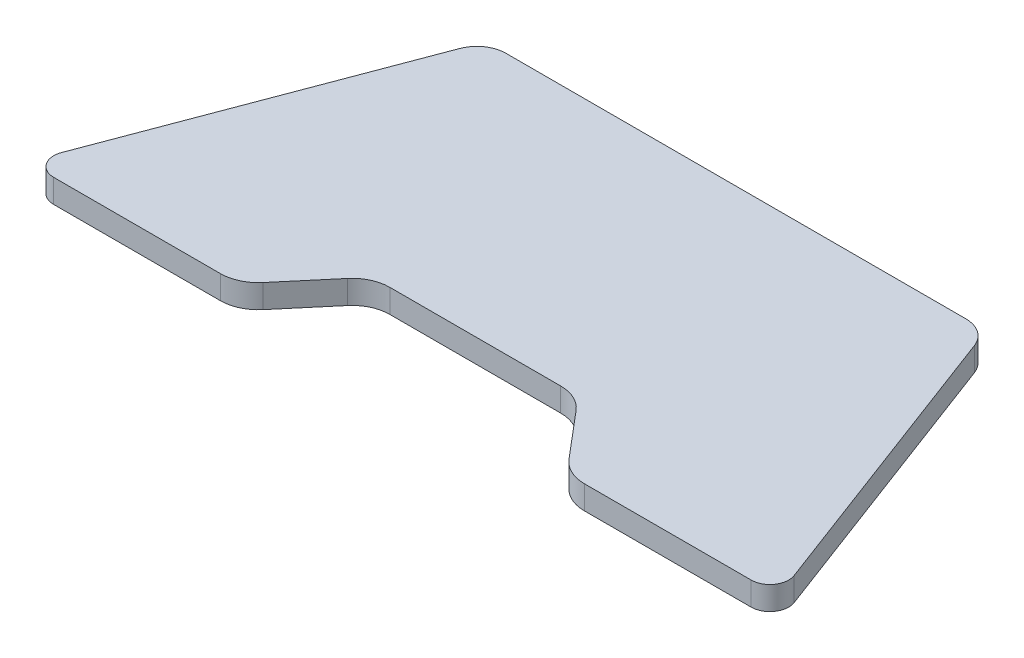
from build123d import *

# Parameters (mm, degrees)
BOSS_EXTRUDE1_DEPTH = 5


with BuildPart() as part:
    # Sketch1 → Boss-Extrude1 (new body)
    with BuildSketch(Plane(origin=(0, 0, 0), x_dir=(1, 0, 0), z_dir=(0, 1, 0))):
        with BuildLine():
            Line((48.939716241, 35.5), (-48.939716241, 35.5))
            ThreePointArc((-48.939716241, 35.5), (-52.484341475, 34.393332114), (-54.769665613, 31.46649501))
            Line((-54.769665613, 31.46649501), (-77.961623751, -30.089730331))
            ThreePointArc((-77.961623751, -30.089730331), (-77.507936909, -33.775842846), (-74.218478088, -35.5))
            Line((-74.218478088, -35.5), (-38.760968174, -35.5))
            ThreePointArc((-38.760968174, -35.5), (-35.349777153, -34.746684682), (-32.573080563, -32.626858226))
            Line((-32.573080563, -32.626858226), (-24.304233813, -22.837670888))
            ThreePointArc((-24.304233813, -22.837670888), (-21.561817428, -20.744015129), (-18.192739876, -20))
            Line((-18.192739876, -20), (0, -20))
            Line((0, -20), (18.192739876, -20))
            ThreePointArc((18.192739876, -20), (21.561817428, -20.744015129), (24.304233813, -22.837670888))
            Line((24.304233813, -22.837670888), (32.573080563, -32.626858226))
            ThreePointArc((32.573080563, -32.626858226), (35.349777153, -34.746684682), (38.760968174, -35.5))
            Line((38.760968174, -35.5), (74.218478088, -35.5))
            ThreePointArc((74.218478088, -35.5), (77.507936909, -33.775842846), (77.961623751, -30.089730331))
            Line((77.961623751, -30.089730331), (54.769665613, 31.46649501))
            ThreePointArc((54.769665613, 31.46649501), (52.484341475, 34.393332114), (48.939716241, 35.5))
        make_face()
    extrude(amount=BOSS_EXTRUDE1_DEPTH)


solid = part.part
